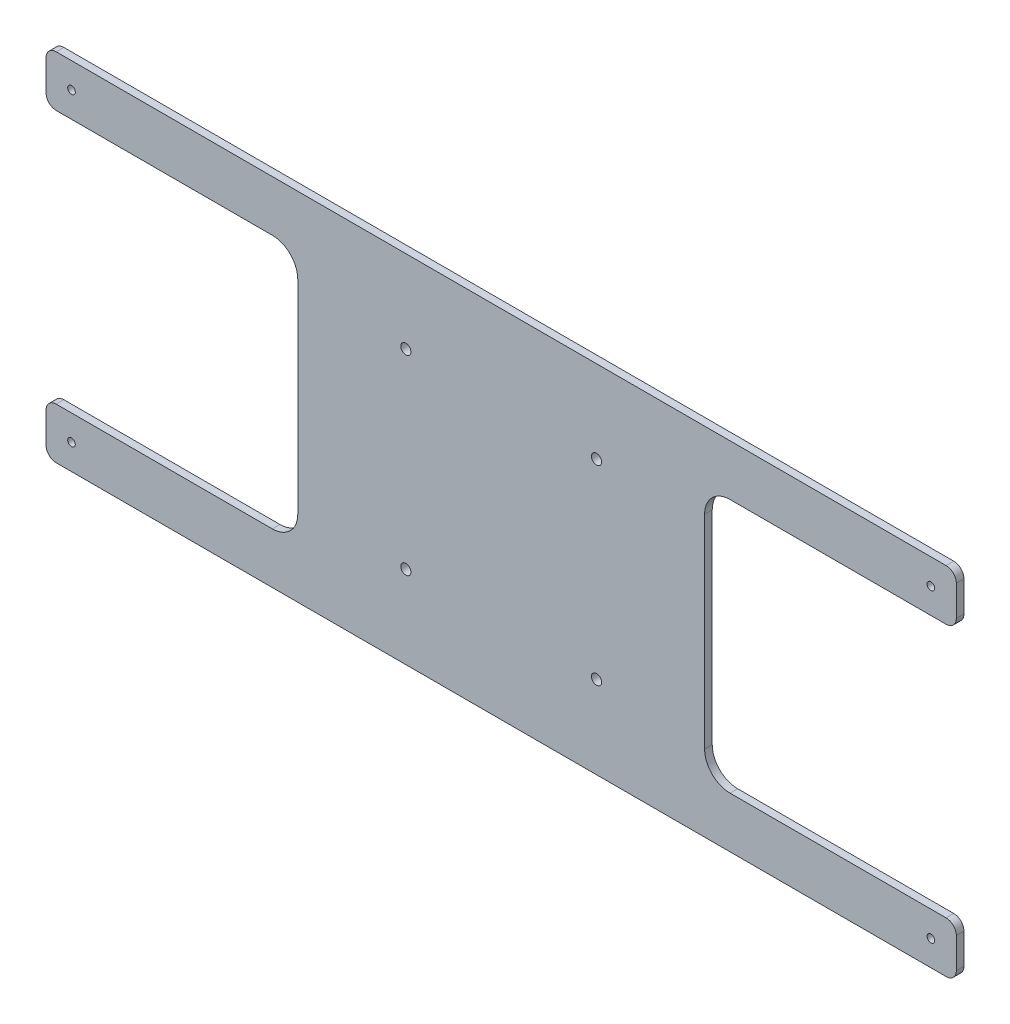
from build123d import *

# Parameters (mm, degrees)
SKETCH1_R           = 1.5
SKETCH1_R_2         = 2
BOSS_EXTRUDE1_DEPTH = 3
FILLET1_R           = 4
FILLET2_R           = 10


with BuildPart() as part:
    # Sketch1 → Boss-Extrude1 (new body)
    with BuildSketch(Plane.XY):
        Polygon((-164.552800631, 70), (164.552800631, 70), (179, 70), (179, 50), (80, 50), (80, -50), (179, -50), (179, -70), (164.552800631, -70), (-164.552800631, -70), (-179, -70), (-179, -50), (-80, -50), (-80, 50), (-179, 50), (-179, 70), align=None)
        with Locations((-169, 60)):
            Circle(SKETCH1_R, mode=Mode.SUBTRACT)
        with Locations((-37.5, 37.5)):
            Circle(SKETCH1_R_2, mode=Mode.SUBTRACT)
        with Locations((37.5, 37.5)):
            Circle(SKETCH1_R_2, mode=Mode.SUBTRACT)
        with Locations((169, 60)):
            Circle(SKETCH1_R, mode=Mode.SUBTRACT)
        with Locations((169, -60)):
            Circle(SKETCH1_R, mode=Mode.SUBTRACT)
        with Locations((37.5, -37.5)):
            Circle(SKETCH1_R_2, mode=Mode.SUBTRACT)
        with Locations((-37.5, -37.5)):
            Circle(SKETCH1_R_2, mode=Mode.SUBTRACT)
        with Locations((-169, -60)):
            Circle(SKETCH1_R, mode=Mode.SUBTRACT)
    extrude(amount=BOSS_EXTRUDE1_DEPTH)

    # Fillet1
    fillet1_edges = [part.edges().sort_by_distance(p)[0] for p in [
        (179, 70, 1.5),
        (179, 50, 1.5),
        (179, -50, 1.5),
        (179, -70, 1.5),
        (-179, -70, 1.5),
        (-179, -50, 1.5),
        (-179, 50, 1.5),
        (-179, 70, 1.5),
    ]]
    fillet(fillet1_edges, radius=FILLET1_R)

    # Fillet2
    fillet2_edges = [part.edges().sort_by_distance(p)[0] for p in [
        (80, 50, 1.5),
        (80, -50, 1.5),
        (-80, -50, 1.5),
        (-80, 50, 1.5),
    ]]
    fillet(fillet2_edges, radius=FILLET2_R)


solid = part.part
